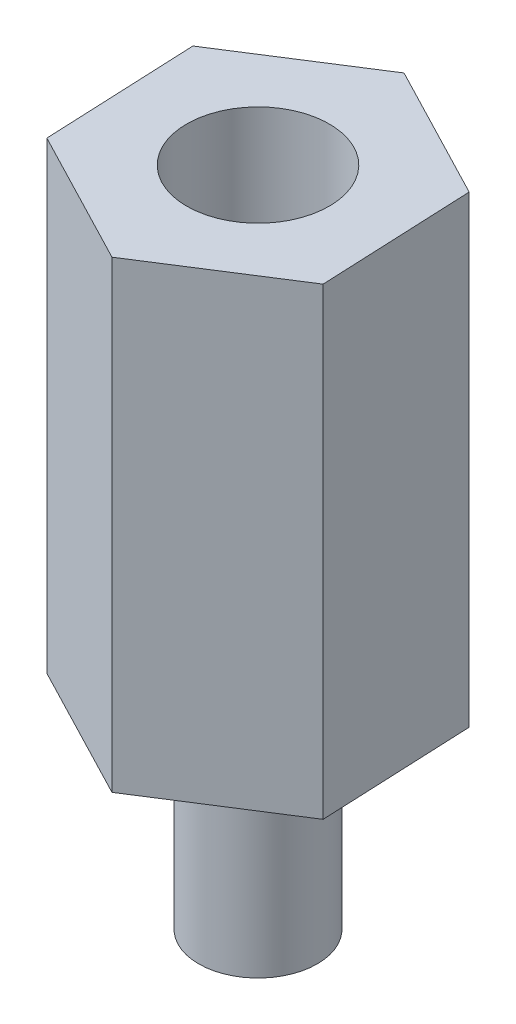
from build123d import *

# Parameters (mm, degrees)
BOSS_EXTRUDE1_DEPTH = 11.1125
SKETCH2_R           = 1.4224
BOSS_EXTRUDE2_DEPTH = 4.7625
SKETCH3_R           = 1.70891155
CUT_EXTRUDE1_DEPTH  = 6.35


with BuildPart() as part:
    # Sketch1 → Boss-Extrude1 (new body)
    with BuildSketch(Plane(origin=(0, 0, 0), x_dir=(1, 0, 0), z_dir=(0, 1, 0))):
        Polygon((3.252691355, -1.691399504), (3.091140616, 1.971213592), (-0.161550739, 3.662613096), (-3.252691355, 1.691399504), (-3.091140616, -1.971213592), (0.161550739, -3.662613096), align=None)
    extrude(amount=BOSS_EXTRUDE1_DEPTH)

    # Sketch2 → Boss-Extrude2 (add)
    with BuildSketch(Plane.XZ):
        Circle(SKETCH2_R)
    extrude(amount=BOSS_EXTRUDE2_DEPTH)

    # Sketch3 → Cut-Extrude1 (cut)
    with BuildSketch(Plane(origin=(0, 11.1125, 0), x_dir=(1, 0, 0), z_dir=(0, 1, 0))):
        Circle(SKETCH3_R)
    extrude(amount=-CUT_EXTRUDE1_DEPTH, mode=Mode.SUBTRACT)


solid = part.part
